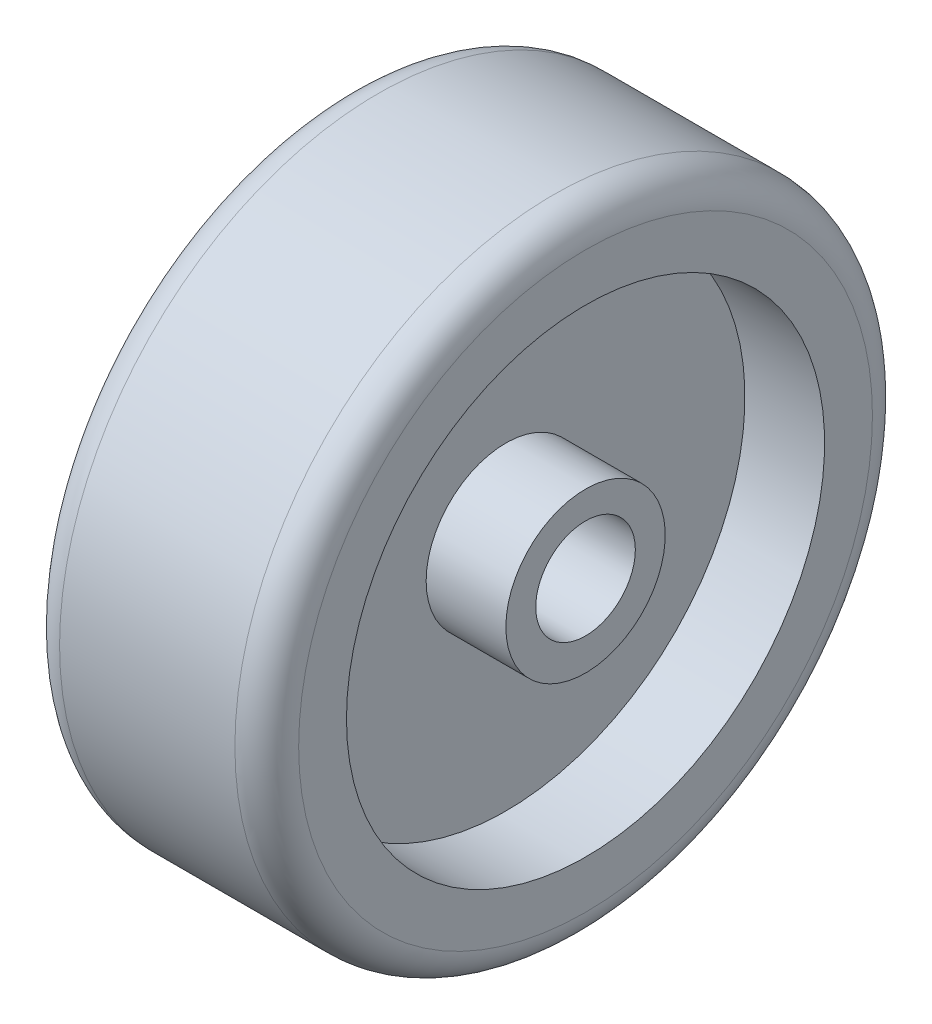
from build123d import *

# Parameters (mm, degrees)
SKETCH2_R          = 15.875
CUT_EXTRUDE1_DEPTH = 77.2
FILLET2_R          = 10.16
FILLET3_R          = 10.16


with BuildPart() as part:
    # Sketch1 → Revolve2 (revolve)
    with BuildSketch(Plane.XY):
        Polygon((-38.1, -0.729526652), (-38.1, 24.670473348), (-12.7, 24.670473348), (-12.7, 75.470473348), (-38.1, 75.470473348), (-38.1, 100.870473348), (38.1, 100.870473348), (38.1, 75.470473348), (12.7, 75.470473348), (12.7, 24.670473348), (38.1, 24.670473348), (38.1, -0.729526652), align=None)
    revolve(axis=Axis((-38.1, -0.729526652, 0), (1, 0, 0)))

    # Sketch2 → Cut-Extrude1 (cut, through all)
    with BuildSketch(Plane(origin=(38.1, 0, 0), x_dir=(0, 0, -1), z_dir=(1, 0, 0))):
        Circle(SKETCH2_R)
    extrude(amount=-CUT_EXTRUDE1_DEPTH, mode=Mode.SUBTRACT)

    # Fillet2
    fillet2_edges = [part.edges().sort_by_distance(p)[0] for p in [
        (38.1, -102.329526652, 0),
    ]]
    fillet(fillet2_edges, radius=FILLET2_R)

    # Fillet3
    fillet3_edges = [part.edges().sort_by_distance(p)[0] for p in [
        (-38.1, -102.329526652, 0),
    ]]
    fillet(fillet3_edges, radius=FILLET3_R)


solid = part.part
